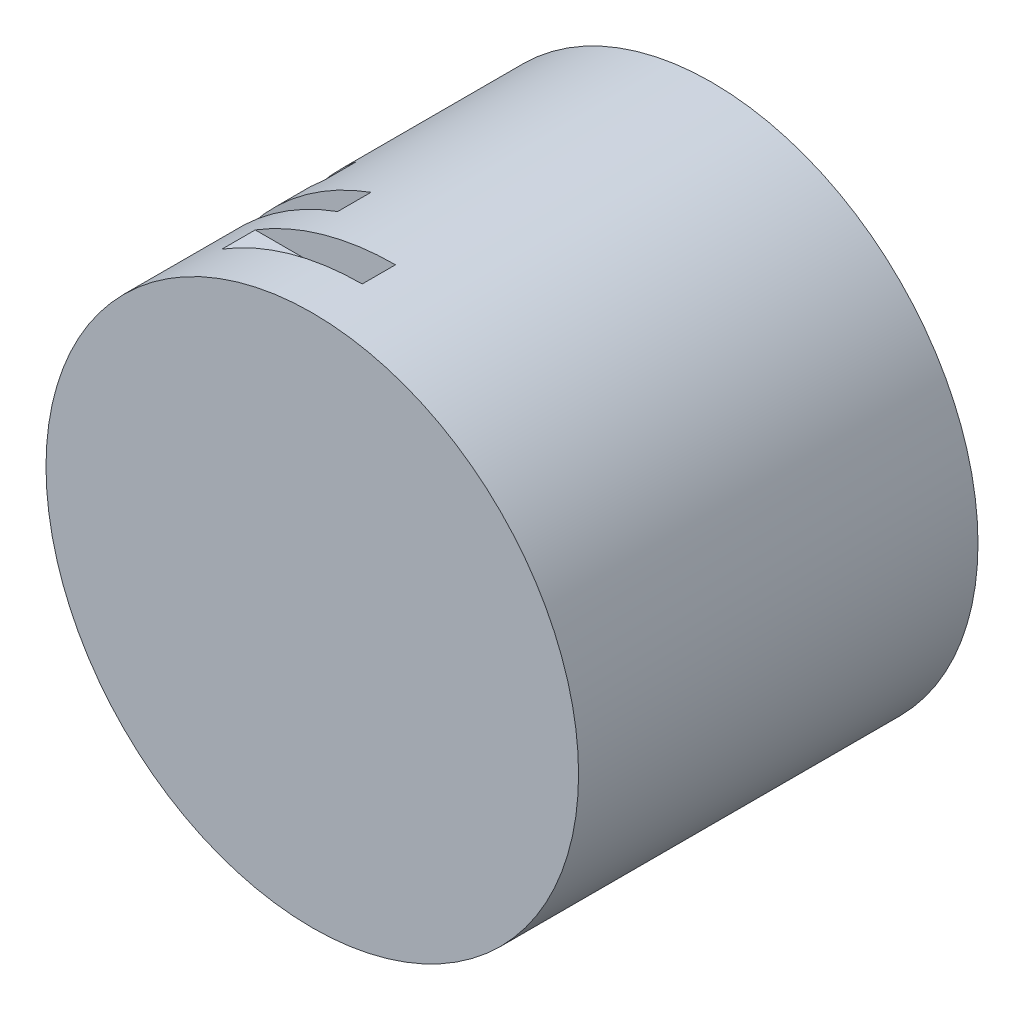
from build123d import *

# Parameters (mm, degrees)
SKIZZE1_R                       = 400
AUFSATZ_LINEAR_AUSTRAGEN1_DEPTH = 300
SCHNITT_LINEAR_AUSTRAGEN1_DEPTH = 25
SCHNITT_LINEAR_AUSTRAGEN2_DEPTH = 25
SCHNITT_LINEAR_AUSTRAGEN3_DEPTH = 25


with BuildPart() as part:
    # Skizze1 → Aufsatz-Linear austragen1 (new body, symmetric)
    with BuildSketch(Plane.XY):
        Circle(SKIZZE1_R)
    extrude(amount=AUFSATZ_LINEAR_AUSTRAGEN1_DEPTH, both=True)

    # Skizze2 → Schnitt-Linear austragen1 (cut, symmetric)
    with BuildSketch(Plane.XY.offset(200)):
        with BuildLine():
            Line((0, 400), (0, 340))
            Line((0, 340), (-210.713075057, 340))
            ThreePointArc((-210.713075057, 340), (-109.544511501, 384.707681233), (0, 400))
        make_face()
    extrude(amount=SCHNITT_LINEAR_AUSTRAGEN1_DEPTH, both=True, mode=Mode.SUBTRACT)

    # Skizze3 → Schnitt-Linear austragen2 (cut, symmetric)
    with BuildSketch(Plane.XY.offset(100)):
        with BuildLine():
            Line((-136.80805733, 375.877048314), (-116.286848731, 319.495491067))
            Line((-116.286848731, 319.495491067), (-314.292370465, 247.427374936))
            ThreePointArc((-314.292370465, 247.427374936), (-234.515945379, 324.040539691), (-136.80805733, 375.877048314))
        make_face()
    extrude(amount=SCHNITT_LINEAR_AUSTRAGEN2_DEPTH, both=True, mode=Mode.SUBTRACT)

    # Skizze4 → Schnitt-Linear austragen3 (cut, symmetric)
    with BuildSketch(Plane.XY):
        with BuildLine():
            Line((-257.115043875, 306.417777248), (-218.547787293, 260.45511066))
            Line((-218.547787293, 260.45511066), (-379.963367533, 125.011356815))
            ThreePointArc((-379.963367533, 125.011356815), (-331.201295158, 224.289326732), (-257.115043875, 306.417777248))
        make_face()
    extrude(amount=SCHNITT_LINEAR_AUSTRAGEN3_DEPTH, both=True, mode=Mode.SUBTRACT)


solid = part.part
